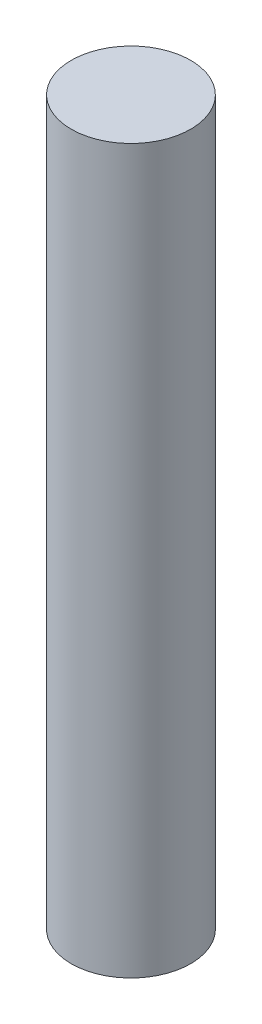
from build123d import *

# Parameters (mm, degrees)
SKETCH1_R           = 9.5
BOSS_EXTRUDE1_DEPTH = 115
CUT_EXTRUDE1_DEPTH  = 6.6


with BuildPart() as part:
    # Sketch1 → Boss-Extrude1 (new body)
    with BuildSketch(Plane(origin=(0, 0, 0), x_dir=(1, 0, 0), z_dir=(0, 1, 0))):
        Circle(SKETCH1_R)
    extrude(amount=BOSS_EXTRUDE1_DEPTH)

    # Sketch2 → Cut-Extrude1 (cut)
    with BuildSketch(Plane.XZ):
        Polygon((1.610807251, 2.79), (-1.610807251, 2.79), (-3.221614502, 0), (-1.610807251, -2.79), (1.610807251, -2.79), (3.221614502, 0), align=None)
    extrude(amount=-CUT_EXTRUDE1_DEPTH, mode=Mode.SUBTRACT)


solid = part.part
